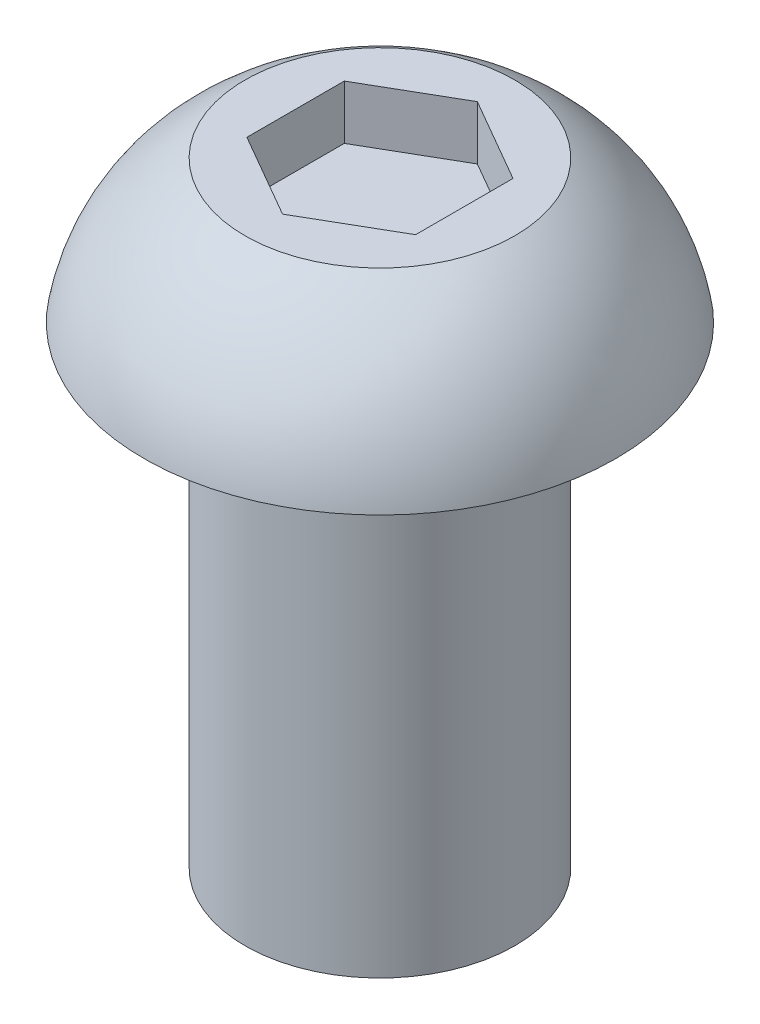
from build123d import *

# Parameters (mm, degrees)
CUT_EXTRUDE1_DEPTH = 1.27


with BuildPart() as part:
    # Sketch1 → Revolve1 (revolve)
    with BuildSketch(Plane.XY):
        with BuildLine():
            Line((-3.175, 0), (-5.5499, 0))
            ThreePointArc((-5.5499, 0), (-4.747091081, 1.948854099), (-3.175, 3.3528))
            Line((-3.175, 3.3528), (0, 3.3528))
            Line((0, 3.3528), (0, -11.1125))
            Line((0, -11.1125), (-3.175, -11.1125))
            Line((-3.175, -11.1125), (-3.175, 0))
        make_face()
    revolve(axis=Axis((0, -11.1125, 0), (0, 1, 0)))

    # Sketch2 → Cut-Extrude1 (cut)
    with BuildSketch(Plane(origin=(0, 3.3528, 0), x_dir=(1, 0, 0), z_dir=(0, 1, 0))):
        Polygon((-1.984375, 1.14567944), (-1.984375, -1.14567944), (0, -2.291358881), (1.984375, -1.14567944), (1.984375, 1.14567944), (0, 2.291358881), align=None)
    extrude(amount=-CUT_EXTRUDE1_DEPTH, mode=Mode.SUBTRACT)


solid = part.part
